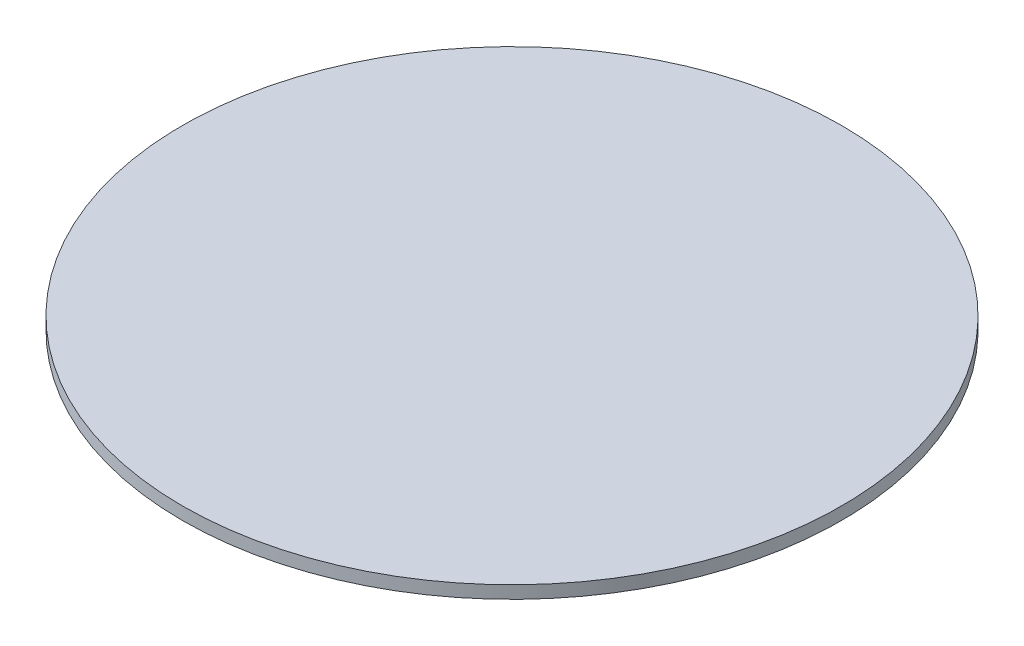
from build123d import *

# Parameters (mm, degrees)
SKETCH1_R           = 79.375
BOSS_EXTRUDE1_DEPTH = 3.048


with BuildPart() as part:
    # Sketch1 → Boss-Extrude1 (new body)
    with BuildSketch(Plane(origin=(0, 0, 0), x_dir=(1, 0, 0), z_dir=(0, 1, 0))):
        Circle(SKETCH1_R)
    extrude(amount=BOSS_EXTRUDE1_DEPTH)


solid = part.part
